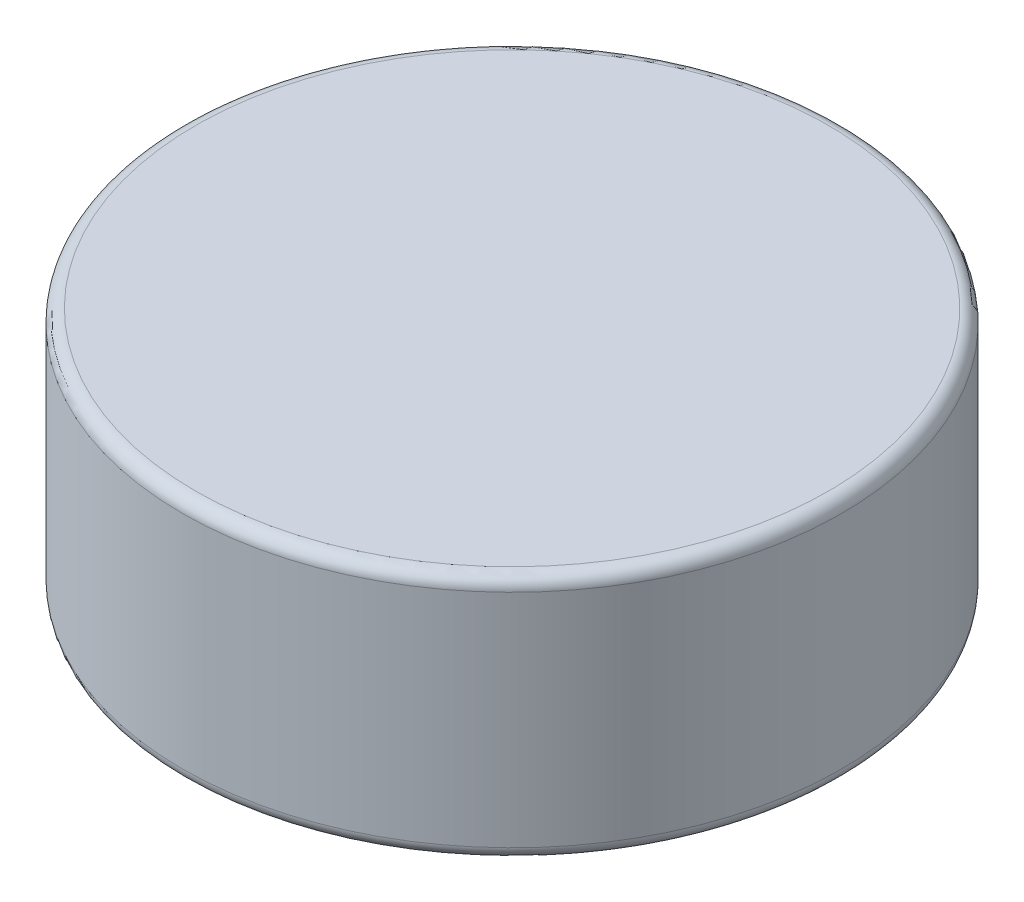
from build123d import *

# Parameters (mm, degrees)
SKETCH1_R           = 12.7
BOSS_EXTRUDE1_DEPTH = 4.7625
FILLET1_R           = 0.5


with BuildPart() as part:
    # Sketch1 → Boss-Extrude1 (new body, symmetric)
    with BuildSketch(Plane(origin=(0, 0, 0), x_dir=(1, 0, 0), z_dir=(0, 1, 0))):
        Circle(SKETCH1_R)
    extrude(amount=BOSS_EXTRUDE1_DEPTH, both=True)

    # Fillet1
    fillet1_edges = [part.edges().sort_by_distance(p)[0] for p in [
        (-12.7, -4.7625, 0),
        (-12.7, 4.7625, 0),
    ]]
    fillet(fillet1_edges, radius=FILLET1_R)


solid = part.part
